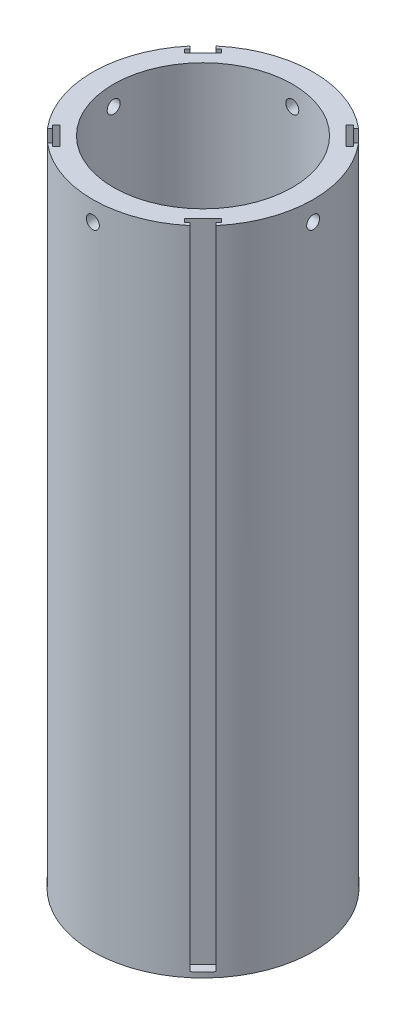
from build123d import *

# Parameters (mm, degrees)
SKETCH1_R               = 42.350766569
SKETCH1_R_2             = 34.350766569
BOSS_EXTRUDE1_DEPTH     = 250
SKETCH2_R               = 2.5
CUT_EXTRUDE1_DEPTH      = 43.350766569
CUT_EXTRUDE1_DEPTH_BACK = 43.350766569
SKETCH3_R               = 2.5
CUT_EXTRUDE2_DEPTH      = 43.350766669
CUT_EXTRUDE2_DEPTH_BACK = 43.350766669
CUT_EXTRUDE3_DEPTH      = 249.0000001
CIRPATTERN1_COUNT       = 4
SKETCH6_R               = 34.350766569
SKETCH6_R_2             = 12.25
BOSS_EXTRUDE3_DEPTH     = 10
SKETCH8_R               = 12.25
BOSS_EXTRUDE6_DEPTH     = 90
SKETCH9_R               = 34.350766569
SKETCH9_R_2             = 9.75
BOSS_EXTRUDE7_DEPTH     = 10


with BuildPart() as part:
    # Sketch1 → Boss-Extrude1 (new body)
    with BuildSketch(Plane(origin=(0, 0, 0), x_dir=(1, 0, 0), z_dir=(0, 1, 0))):
        Circle(SKETCH1_R)
        Circle(SKETCH1_R_2, mode=Mode.SUBTRACT)
    extrude(amount=BOSS_EXTRUDE1_DEPTH)

    # Sketch2 → Cut-Extrude1 (cut, two sides)
    with BuildSketch(Plane(origin=(0, 0, 0), x_dir=(0, 0, -1), z_dir=(1, 0, 0))) as cut_extrude1_sk:
        with Locations((0, 242.5)):
            Circle(SKETCH2_R)
    extrude(amount=CUT_EXTRUDE1_DEPTH, mode=Mode.SUBTRACT)
    extrude(cut_extrude1_sk.sketch, amount=-CUT_EXTRUDE1_DEPTH_BACK, mode=Mode.SUBTRACT)

    # Sketch3 → Cut-Extrude2 (cut, two sides)
    with BuildSketch(Plane.XY) as cut_extrude2_sk:
        with Locations((0, 242.5)):
            Circle(SKETCH3_R)
    extrude(amount=CUT_EXTRUDE2_DEPTH, mode=Mode.SUBTRACT)
    extrude(cut_extrude2_sk.sketch, amount=-CUT_EXTRUDE2_DEPTH_BACK, mode=Mode.SUBTRACT)

    # Sketch4 → Cut-Extrude3 (cut, through all)
    with BuildSketch(Plane(origin=(0, 2, 0), x_dir=(1, 0, 0), z_dir=(0, 1, 0))):
        with BuildLine():
            Line((31.007174401, 23.936106589), (23.936106589, 31.007174401))
            Line((23.936106589, 31.007174401), (25.350320151, 32.421387963))
            Line((25.350320151, 32.421387963), (26.410980323, 31.360727791))
            Line((26.410980323, 31.360727791), (27.369199622, 32.31894709))
            ThreePointArc((27.369199622, 32.31894709), (29.946514229, 29.946514229), (32.31894709, 27.369199622))
            Line((32.31894709, 27.369199622), (31.360727791, 26.410980323))
            Line((31.360727791, 26.410980323), (32.421387963, 25.350320151))
            Line((32.421387963, 25.350320151), (31.007174401, 23.936106589))
        make_face()
    cut_extrude3 = extrude(amount=CUT_EXTRUDE3_DEPTH, mode=Mode.SUBTRACT)

    # CirPattern1: Cut-Extrude3 ×4 about axis
    cirpattern1_axis = Axis((0, 0, 0), (0, 1, 0))
    for i in range(1, CIRPATTERN1_COUNT):
        add(cut_extrude3.rotate(cirpattern1_axis, i * 360 / CIRPATTERN1_COUNT), mode=Mode.SUBTRACT)

    # Sketch6 → Boss-Extrude3 (add)
    with BuildSketch(Plane(origin=(0, 0, 0), x_dir=(1, 0, 0), z_dir=(0, 1, 0))):
        Circle(SKETCH6_R)
        with Locations((-13.281800184, 13.281800184)):
            Circle(SKETCH6_R_2, mode=Mode.SUBTRACT)
        with Locations((13.281800184, 13.281800184)):
            Circle(SKETCH6_R_2, mode=Mode.SUBTRACT)
        with Locations((13.281800184, -13.281800184)):
            Circle(SKETCH6_R_2, mode=Mode.SUBTRACT)
        with Locations((-13.281800184, -13.281800184)):
            Circle(SKETCH6_R_2, mode=Mode.SUBTRACT)
    extrude(amount=BOSS_EXTRUDE3_DEPTH)

    # Sketch8 → Boss-Extrude6 (add)
    with BuildSketch(Plane(origin=(0, 10, 0), x_dir=(1, 0, 0), z_dir=(0, 1, 0))):
        with BuildLine():
            ThreePointArc((0, 13.281800184), (-22.67345116, 22.67345116), (-13.281800184, 0))
            ThreePointArc((-13.281800184, 0), (-22.67345116, -22.67345116), (0, -13.281800184))
            ThreePointArc((0, -13.281800184), (22.67345116, -22.67345116), (13.281800184, 0))
            ThreePointArc((13.281800184, 0), (22.67345116, 22.67345116), (0, 13.281800184))
        make_face()
        with Locations((-13.281800184, -13.281800184)):
            Circle(SKETCH8_R, mode=Mode.SUBTRACT)
        with Locations((13.281800184, -13.281800184)):
            Circle(SKETCH8_R, mode=Mode.SUBTRACT)
        with Locations((13.281800184, 13.281800184)):
            Circle(SKETCH8_R, mode=Mode.SUBTRACT)
        with Locations((-13.281800184, 13.281800184)):
            Circle(SKETCH8_R, mode=Mode.SUBTRACT)
    extrude(amount=BOSS_EXTRUDE6_DEPTH)

    # Sketch9 → Boss-Extrude7 (add)
    with BuildSketch(Plane(origin=(0, 100, 0), x_dir=(1, 0, 0), z_dir=(0, 1, 0))):
        Circle(SKETCH9_R)
        with Locations((-13.281800184, 13.281800184)):
            Circle(SKETCH9_R_2, mode=Mode.SUBTRACT)
        with Locations((13.281800184, 13.281800184)):
            Circle(SKETCH9_R_2, mode=Mode.SUBTRACT)
        with Locations((13.281800184, -13.281800184)):
            Circle(SKETCH9_R_2, mode=Mode.SUBTRACT)
        with Locations((-13.281800184, -13.281800184)):
            Circle(SKETCH9_R_2, mode=Mode.SUBTRACT)
    extrude(amount=BOSS_EXTRUDE7_DEPTH)


solid = part.part
